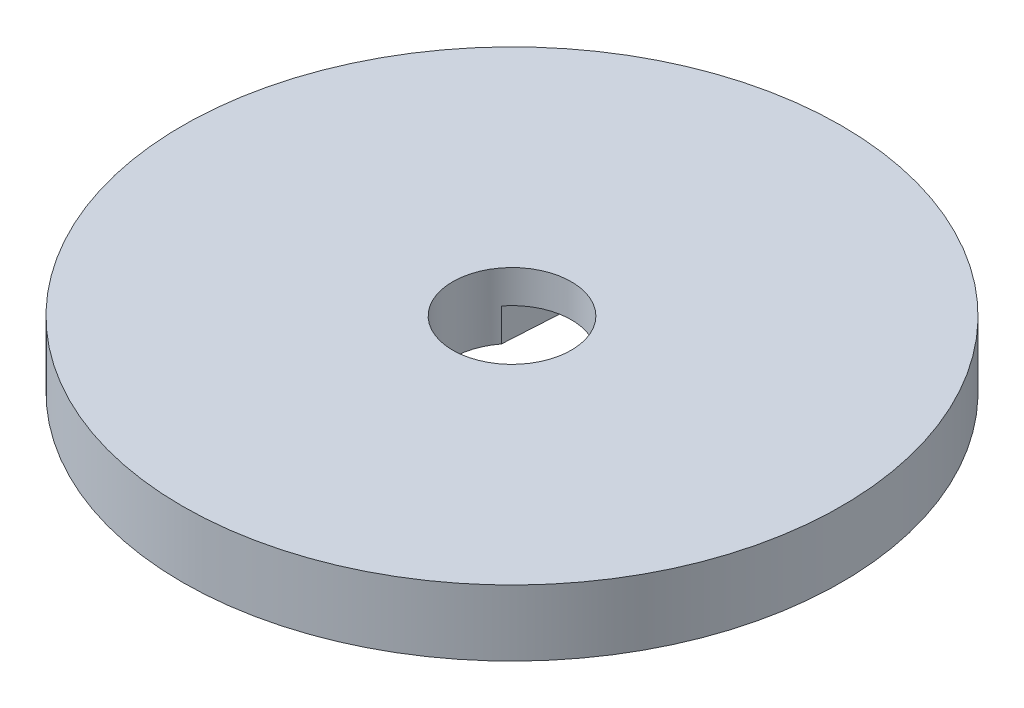
from build123d import *

# Parameters (mm, degrees)
SKETCH1_R           = 20
SKETCH1_R_2         = 3.6
BOSS_EXTRUDE2_DEPTH = 4
CUT_EXTRUDE2_DEPTH  = 2


with BuildPart() as part:
    # Sketch1 → Boss-Extrude2 (new body)
    with BuildSketch(Plane(origin=(0, 0, 0), x_dir=(1, 0, 0), z_dir=(0, 1, 0))):
        Circle(SKETCH1_R)
        Circle(SKETCH1_R_2, mode=Mode.SUBTRACT)
    extrude(amount=BOSS_EXTRUDE2_DEPTH)

    # Sketch1_6 → Cut-Extrude2 (cut)
    with BuildSketch(Plane(origin=(0, 0, 0), x_dir=(1, 0, 0), z_dir=(0, 1, 0))):
        with BuildLine():
            Line((-2.847996741, -2.202025105), (-1.999997781, -16.602979385))
            ThreePointArc((-1.999997781, -16.602979385), (0, -18.6), (1.999997781, -16.602979385))
            Line((1.999997781, -16.602979385), (2.847996741, -2.202025105))
            ThreePointArc((2.847996741, -2.202025105), (0, -3.6), (-2.847996741, -2.202025105))
        make_face()
        with BuildLine():
            ThreePointArc((-2.847996741, 2.202025105), (0, 3.6), (2.847996741, 2.202025105))
            Line((2.847996741, 2.202025105), (1.999997781, 16.602979385))
            ThreePointArc((1.999997781, 16.602979385), (0, 18.6), (-1.999997781, 16.602979385))
            Line((-1.999997781, 16.602979385), (-2.847996741, 2.202025105))
        make_face()
    extrude(amount=CUT_EXTRUDE2_DEPTH, mode=Mode.SUBTRACT)


solid = part.part
